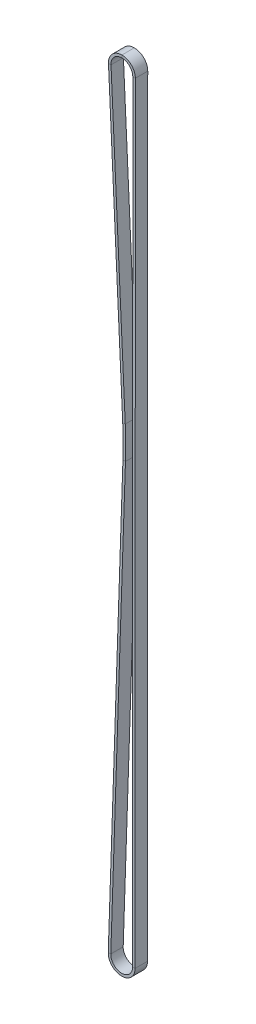
from build123d import *

# Parameters (mm, degrees)
SKETCH4_W = 7.366
SKETCH4_H = 1.5


with BuildPart() as part:
    # Sweep1: sweep along a path in Sketch2
    with BuildLine(Plane.XY) as sweep1_path:
        Line((7.091056719, -457.202005016), (7.218056719, -0.002005016))
        ThreePointArc((7.218056719, -0.002005016), (-0.16802341, 7.216101091), (-7.210140832, -0.33795859))
        Line((-7.210140832, -0.33795859), (1.239489336, -180.605675903))
        ThreePointArc((1.239489336, -180.605675903), (1.493988432, -190.144726502), (1.363674734, -199.686281641))
        Line((1.363674734, -199.686281641), (-7.340929008, -456.955919922))
        ThreePointArc((-7.340929008, -456.955919922), (-0.250059855, -464.417007904), (7.091056719, -457.202005016))
    # Sketch4 → Sweep1 (sweep)
    with BuildSketch(Plane(origin=(0, 0, 0), x_dir=(0, 0, -1), z_dir=(1, 0, 0))):
        with Locations((-3.683, 7.218056998)):
            Rectangle(SKETCH4_W, SKETCH4_H)
    sweep(path=sweep1_path.line)


solid = part.part
